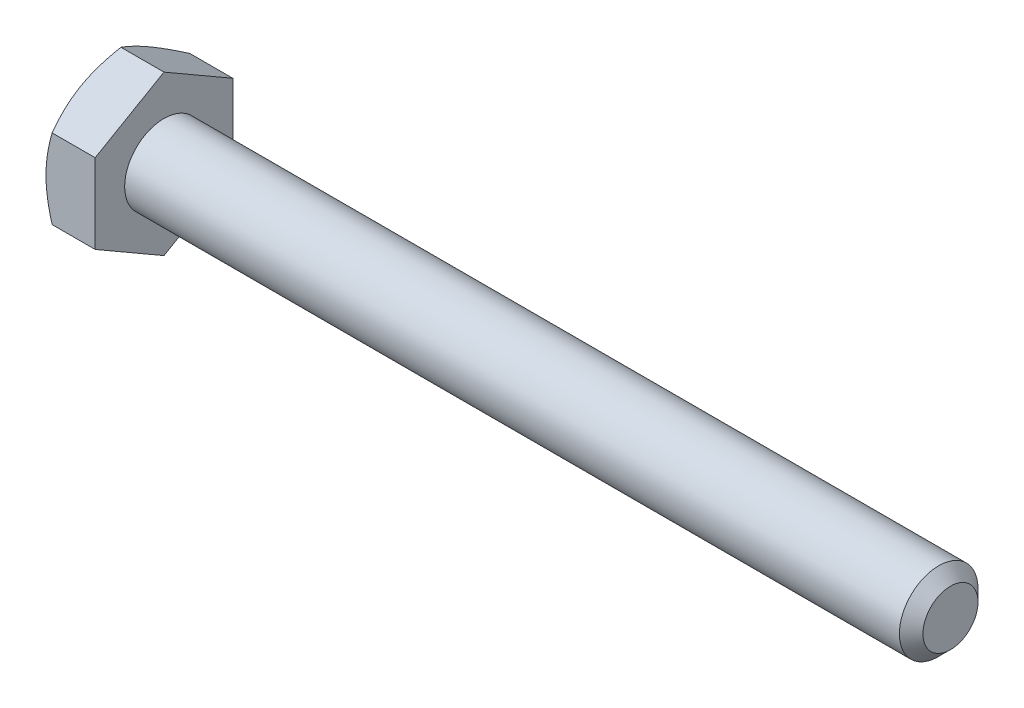
from build123d import *

# Parameters (mm, degrees)
SKETCH5_R           = 3.175
BOSS_EXTRUDE3_DEPTH = 63.5
CHAMFER1_SIZE       = 0.9525
BOSS_EXTRUDE4_DEPTH = 3.96875
SKETCH8_OUTSIDE_W   = 264.208
SKETCH8_OUTSIDE_H   = 265.928
SKETCH8_OUTSIDE_R   = 5.55625
CUT_EXTRUDE3_DEPTH  = 68.46875
CUT_EXTRUDE3_TAPER  = 60
CUT_EXTRUDE4_DEPTH  = 0.254
CIRPATTERN1_COUNT   = 3


with BuildPart() as part:
    # Sketch5 → Boss-Extrude3 (new body)
    with BuildSketch(Plane(origin=(33.734375, 0, 0), x_dir=(0, 0, -1), z_dir=(1, 0, 0))):
        Circle(SKETCH5_R)
    extrude(amount=-BOSS_EXTRUDE3_DEPTH)

    # Chamfer1
    chamfer1_edges = [part.edges().sort_by_distance(p)[0] for p in [
        (33.734375, 0, 3.175),
    ]]
    chamfer(chamfer1_edges, length=CHAMFER1_SIZE)

    # Sketch11 → Revolve1 (revolve)
    with BuildSketch(Plane.XY):
        Polygon((-29.765625, 3.175), (-29.765625, 0), (17.859375, 0), (14.684375, 3.175), align=None)
    revolve(axis=Axis((-29.765625, 0, 0), (1, 0, 0)))

    # Sketch6 → Boss-Extrude4 (add)
    with BuildSketch(Plane.ZY.offset(29.765625)):
        Polygon((5.55625, 3.207902433), (0, 6.415804866), (-5.55625, 3.207902433), (-5.55625, -3.207902433), (0, -6.415804866), (5.55625, -3.207902433), align=None)
    extrude(amount=BOSS_EXTRUDE4_DEPTH)

    # Sketch8 outside → Cut-Extrude3 (cut, through all)
    with BuildSketch(Plane.ZY.offset(33.734375)):
        Rectangle(SKETCH8_OUTSIDE_W, SKETCH8_OUTSIDE_H)
        Circle(SKETCH8_OUTSIDE_R, mode=Mode.SUBTRACT)
    extrude(amount=-CUT_EXTRUDE3_DEPTH, taper=CUT_EXTRUDE3_TAPER, mode=Mode.SUBTRACT)

    # Sketch12 → Cut-Extrude4 (cut)
    with BuildSketch(Plane.ZY.offset(33.734375)):
        with BuildLine():
            Line((0.1666875, 4.2783125), (0.1666875, 2.3891875))
            ThreePointArc((0.1666875, 2.3891875), (0, 2.2225), (-0.1666875, 2.3891875))
            Line((-0.1666875, 2.3891875), (-0.1666875, 4.2783125))
            ThreePointArc((-0.1666875, 4.2783125), (0, 4.445), (0.1666875, 4.2783125))
        make_face()
    cut_extrude4 = extrude(amount=-CUT_EXTRUDE4_DEPTH, mode=Mode.SUBTRACT)

    # CirPattern1: Cut-Extrude4 ×3 about axis
    cirpattern1_axis = Axis((0, 0, 0), (1, 0, 0))
    for i in range(1, CIRPATTERN1_COUNT):
        add(cut_extrude4.rotate(cirpattern1_axis, i * 360 / CIRPATTERN1_COUNT), mode=Mode.SUBTRACT)


solid = part.part
